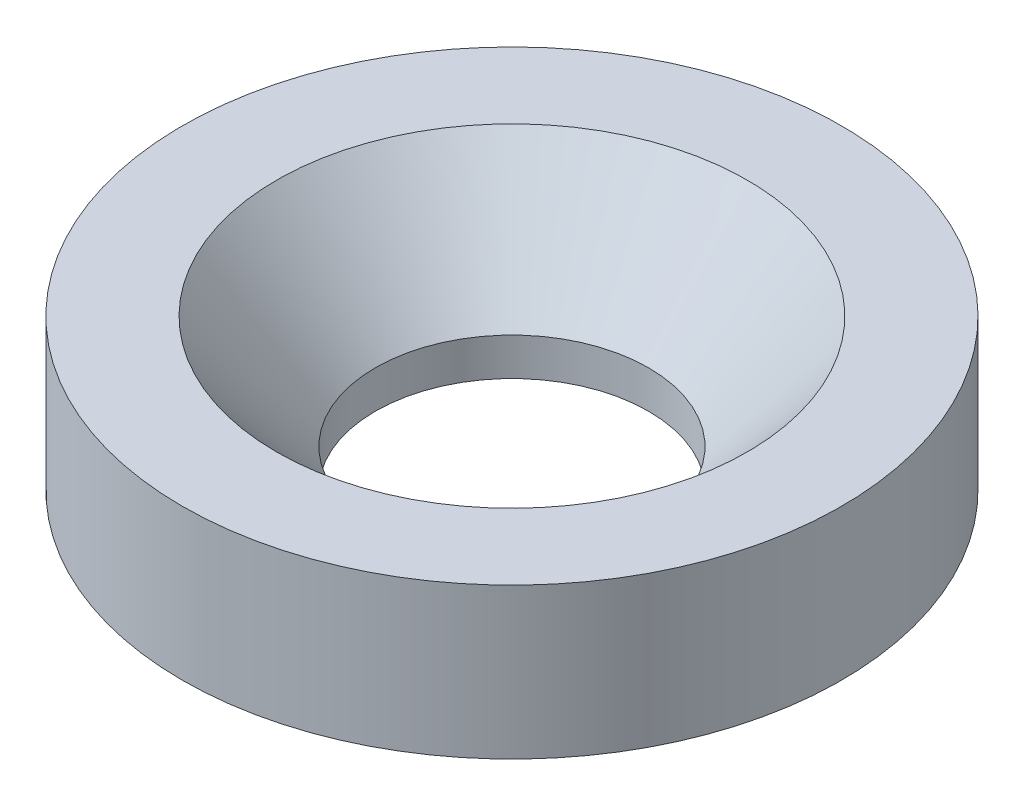
from build123d import *


with BuildPart() as part:
    # Sketch1 → Revolve1 (revolve)
    with BuildSketch(Plane.XY):
        Polygon((7.25, -65.124826934), (17.5, -65.124826934), (17.5, -57.124826934), (12.5, -57.124826934), (7.25, -63.124826934), align=None)
    revolve(axis=Axis((0, 54.442977014, 0), (0, -1, 0)))


solid = part.part
